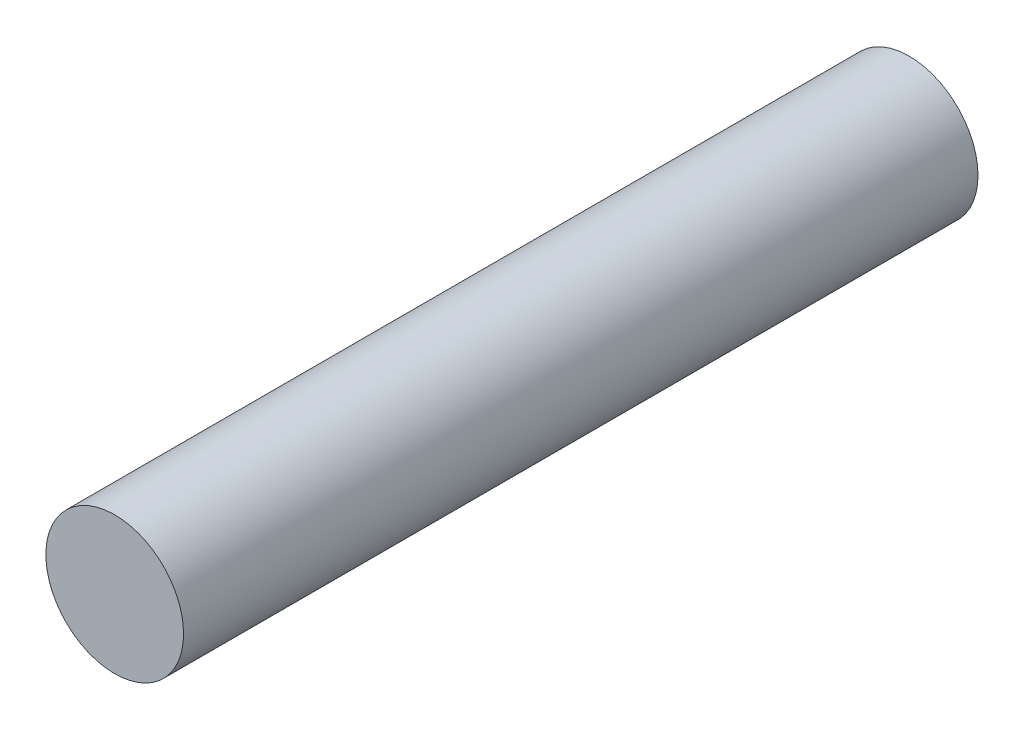
from build123d import *

# Parameters (mm, degrees)
SKETCH1_R           = 6.5
BOSS_EXTRUDE1_DEPTH = 37.5


with BuildPart() as part:
    # Sketch1 → Boss-Extrude1 (new body, symmetric)
    with BuildSketch(Plane.XY):
        Circle(SKETCH1_R)
    extrude(amount=BOSS_EXTRUDE1_DEPTH, both=True)


solid = part.part
